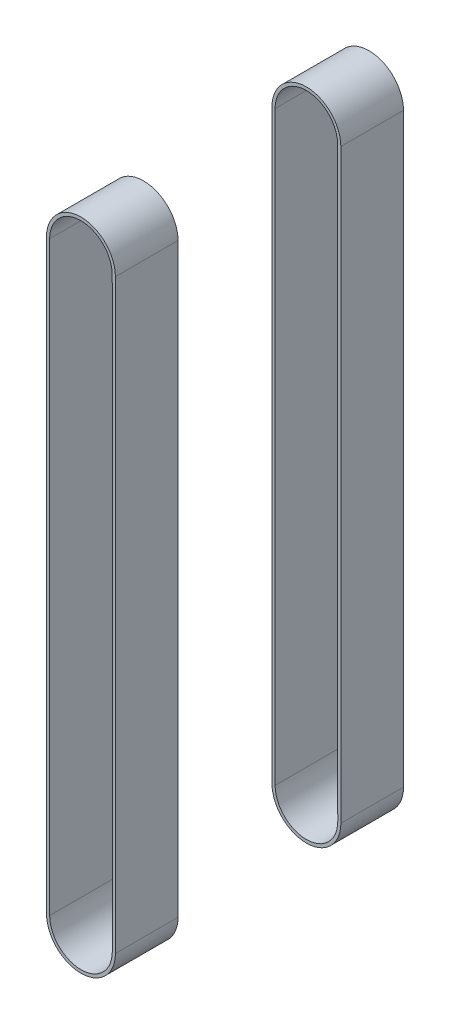
from build123d import *

# Parameters (mm, degrees)
BOSS_EXTRUDE1_START = 16.51
BOSS_EXTRUDE1_DEPTH = 12.7


with BuildPart() as part:
    # Sketch1 → Boss-Extrude1 (new body)
    with BuildSketch(Plane.XY.offset(BOSS_EXTRUDE1_START)):
        with BuildLine():
            Line((284.597674513, 88.078143699), (284.606648072, -30.769188909))
            ThreePointArc((284.606648072, -30.769188909), (291.592175454, -37.753661487), (298.576648032, -30.768134106))
            Line((298.576648032, -30.768134106), (298.567674474, 88.079198502))
            ThreePointArc((298.567674474, 88.079198502), (291.582147092, 95.06367108), (284.597674513, 88.078143699))
        make_face()
        with BuildLine():
            Line((285.232674512, 88.078191644), (285.24164807, -30.769140964))
            ThreePointArc((285.24164807, -30.769140964), (291.592127508, -37.118661489), (297.941648034, -30.768182051))
            Line((297.941648034, -30.768182051), (297.932674475, 88.079150557))
            ThreePointArc((297.932674475, 88.079150557), (291.582195037, 94.428671082), (285.232674512, 88.078191644))
        make_face(mode=Mode.SUBTRACT)
    extrude(amount=BOSS_EXTRUDE1_DEPTH)


with BuildPart() as body_2:
    # Mirror2: mirrored copy
    add(part.part.mirror(Plane.XY))


solid = Compound([part.part, body_2.part])
